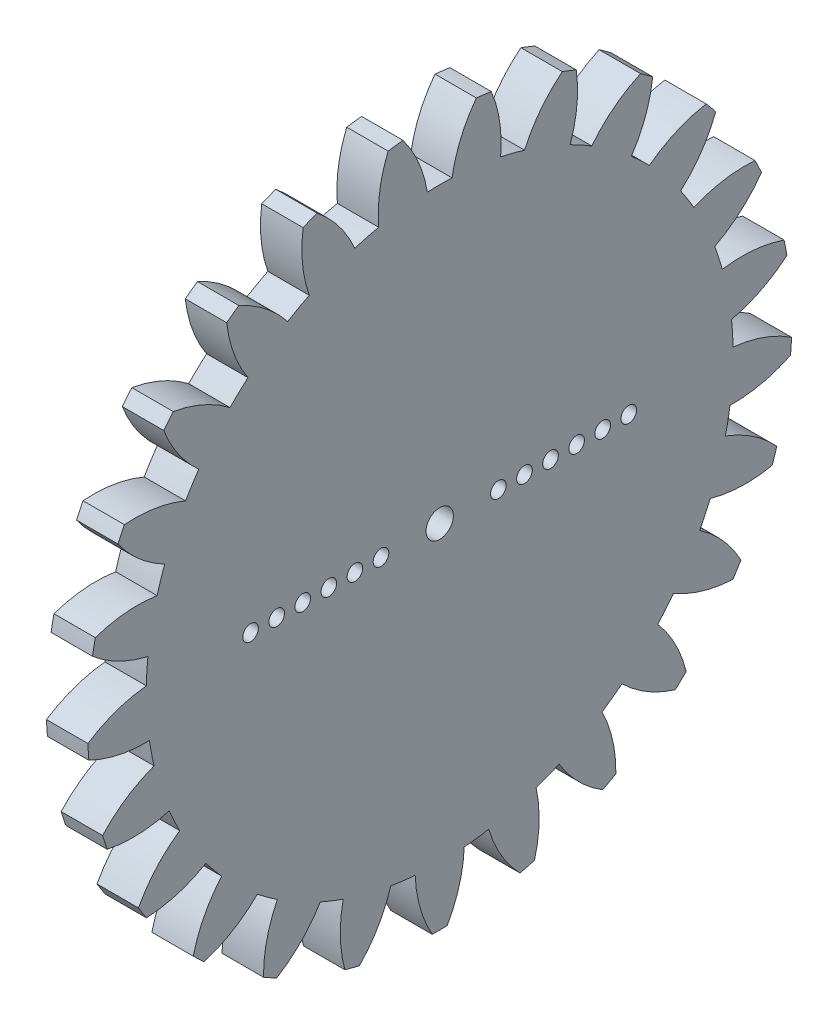
from build123d import *

# Parameters (mm, degrees)
BASPROSKE_W        = 10
BASPROSKE_H        = 27
TOOTHCUT_DEPTH     = 40.471508712
TEETHCUTS_COUNT    = 25
CUT_EXTRUDE1_DEPTH = 6.825
SKETCH2_R          = 1.05
SKETCH2_R_2        = 0.6
CUT_EXTRUDE2_DEPTH = 39.299167466


with BuildPart() as part:
    # BasProSke → Base-Revolve (revolve)
    with BuildSketch(Plane(origin=(0, 0, 0), x_dir=(1, 0, 0), z_dir=(0, 1, 0)), mode=Mode.PRIVATE) as base_revolve_sk:
        with Locations((5, 13.5)):
            Rectangle(BASPROSKE_W, BASPROSKE_H)
    revolve(base_revolve_sk.sketch.rotate(Axis((-10, 0, 0), (1, 0, 0)), 180), axis=Axis((-10, 0, 0), (1, 0, 0)))

    # TooCutSke → ToothCut (cut, through all)
    with BuildSketch(Plane(origin=(0, 0, 0), x_dir=(0, 0, -1), z_dir=(1, 0, 0))):
        with BuildLine():
            ThreePointArc((0.946154762, 22.479096783), (0, 22.499), (-0.946154762, 22.479096783))
            ThreePointArc((-0.946154762, 22.479096783), (-1.62094792, 24.792268013), (-2.829470045, 26.876873784))
            ThreePointArc((-2.829470045, 26.876873784), (0, 27.0254), (2.829470045, 26.876873784))
            ThreePointArc((2.829470045, 26.876873784), (1.62094792, 24.792268013), (0.946154762, 22.479096783))
        make_face()
    toothcut = extrude(amount=TOOTHCUT_DEPTH, mode=Mode.SUBTRACT)

    # TeethCuts: ToothCut ×25 about axis
    teethcuts_axis = Axis((0, 0, 0), (1, 0, 0))
    for i in range(1, TEETHCUTS_COUNT):
        add(toothcut.rotate(teethcuts_axis, i * 360 / TEETHCUTS_COUNT), mode=Mode.SUBTRACT)

    # Sketch1 → Cut-Extrude1 (cut)
    with BuildSketch(Plane(origin=(10, 0, 0), x_dir=(0, 0, -1), z_dir=(1, 0, 0))):
        with BuildLine():
            ThreePointArc((-26.623667603, 4.492251481), (-24.628342026, 3.167806143), (-22.375329871, 2.355761908))
            ThreePointArc((-22.375329871, 2.355761908), (-22.454603363, 1.412723899), (-22.494148969, 0.467186424))
            ThreePointArc((-22.494148969, 0.467186424), (-24.83117158, -0.056077302), (-26.976760436, -1.119998387))
            ThreePointArc((-26.976760436, -1.119998387), (-26.946721668, -1.695344027), (-26.904413642, -2.269917752))
            ThreePointArc((-26.904413642, -2.269917752), (-24.642398725, -3.056535912), (-22.258221901, -3.282766946))
            ThreePointArc((-22.258221901, -3.282766946), (-22.100480854, -4.215892197), (-21.903638454, -5.141558466))
            ThreePointArc((-21.903638454, -5.141558466), (-24.037108806, -6.229576789), (-25.850703628, -7.793659087))
            ThreePointArc((-25.850703628, -7.793659087), (-25.67852594, -8.343458848), (-25.494656424, -8.889459704))
            ThreePointArc((-25.494656424, -8.889459704), (-23.108082884, -9.088824574), (-20.742547988, -8.715027478))
            ThreePointArc((-20.742547988, -8.715027478), (-20.357703853, -9.579608281), (-19.93684178, -10.427240328))
            ThreePointArc((-19.93684178, -10.427240328), (-21.732706083, -12.011649055), (-23.100352038, -13.977615523))
            ThreePointArc((-23.100352038, -13.977615523), (-22.796853989, -14.467323464), (-22.48297618, -14.95044421))
            ThreePointArc((-22.48297618, -14.95044421), (-20.12180121, -14.550028962), (-17.9235435, -13.599690783))
            ThreePointArc((-17.9235435, -13.599690783), (-17.335777449, -14.341402345), (-16.717340013, -15.057740331))
            ThreePointArc((-16.717340013, -15.057740331), (-18.06275751, -17.038985236), (-18.898520373, -19.28330697))
            ThreePointArc((-18.898520373, -19.28330697), (-18.48277186, -19.68215294), (-18.058607856, -20.072037323))
            ThreePointArc((-18.058607856, -20.072037323), (-15.871192762, -19.097001519), (-13.978336856, -17.6298355))
            ThreePointArc((-13.978336856, -17.6298355), (-13.224580391, -18.202073356), (-12.447426292, -18.742107131))
            ThreePointArc((-12.447426292, -18.742107131), (-13.257859452, -20.995699309), (-13.509225169, -23.377357322))
            ThreePointArc((-13.509225169, -23.377357322), (-13.007349201, -23.660280361), (-12.499550786, -23.932430511))
            ThreePointArc((-12.499550786, -23.932430511), (-10.623338904, -22.444039237), (-9.154819898, -20.552232814))
            ThreePointArc((-9.154819898, -20.552232814), (-8.282434311, -20.919041156), (-7.395394998, -21.248838411))
            ThreePointArc((-7.395394998, -21.248838411), (-7.619921325, -23.633176378), (-7.271095664, -26.002522336))
            ThreePointArc((-7.271095664, -26.002522336), (-6.714626953, -26.15174535), (-6.15510097, -26.289061072))
            ThreePointArc((-6.15510097, -26.289061072), (-4.707981592, -24.380835426), (-3.756071937, -22.183257755))
            ThreePointArc((-3.756071937, -22.183257755), (-2.819872422, -22.321588665), (-1.878683838, -22.420427026))
            ThreePointArc((-1.878683838, -22.420427026), (-1.503195518, -24.785694058), (-0.576096477, -26.993853242))
            ThreePointArc((-0.576096477, -26.993853242), (0, -27), (0.576096477, -26.993853242))
            ThreePointArc((0.576096477, -26.993853242), (1.503195518, -24.785694058), (1.878683838, -22.420427026))
            ThreePointArc((1.878683838, -22.420427026), (2.819872422, -22.321588665), (3.756071937, -22.183257755))
            ThreePointArc((3.756071937, -22.183257755), (4.707981592, -24.380835426), (6.15510097, -26.289061072))
            ThreePointArc((6.15510097, -26.289061072), (6.714626953, -26.15174535), (7.271095664, -26.002522336))
            ThreePointArc((7.271095664, -26.002522336), (7.619921325, -23.633176378), (7.395394998, -21.248838411))
            ThreePointArc((7.395394998, -21.248838411), (8.282434311, -20.919041156), (9.154819898, -20.552232814))
            ThreePointArc((9.154819898, -20.552232814), (10.623338904, -22.444039237), (12.499550786, -23.932430511))
            ThreePointArc((12.499550786, -23.932430511), (13.007349201, -23.660280361), (13.509225169, -23.377357322))
            ThreePointArc((13.509225169, -23.377357322), (13.257859452, -20.995699309), (12.447426292, -18.742107131))
            ThreePointArc((12.447426292, -18.742107131), (13.224580391, -18.202073356), (13.978336856, -17.6298355))
            ThreePointArc((13.978336856, -17.6298355), (15.871192762, -19.097001519), (18.058607856, -20.072037323))
            ThreePointArc((18.058607856, -20.072037323), (18.48277186, -19.68215294), (18.898520373, -19.28330697))
            ThreePointArc((18.898520373, -19.28330697), (18.06275751, -17.038985236), (16.717340013, -15.057740331))
            ThreePointArc((16.717340013, -15.057740331), (17.335777449, -14.341402345), (17.9235435, -13.599690783))
            ThreePointArc((17.9235435, -13.599690783), (20.12180121, -14.550028962), (22.48297618, -14.95044421))
            ThreePointArc((22.48297618, -14.95044421), (22.796853989, -14.467323464), (23.100352038, -13.977615523))
            ThreePointArc((23.100352038, -13.977615523), (21.732706083, -12.011649055), (19.93684178, -10.427240328))
            ThreePointArc((19.93684178, -10.427240328), (20.357703853, -9.579608281), (20.742547988, -8.715027478))
            ThreePointArc((20.742547988, -8.715027478), (23.108082884, -9.088824574), (25.494656424, -8.889459704))
            ThreePointArc((25.494656424, -8.889459704), (25.67852594, -8.343458848), (25.850703628, -7.793659087))
            ThreePointArc((25.850703628, -7.793659087), (24.037108806, -6.229576789), (21.903638454, -5.141558466))
            ThreePointArc((21.903638454, -5.141558466), (22.100480854, -4.215892197), (22.258221901, -3.282766946))
            ThreePointArc((22.258221901, -3.282766946), (24.642398725, -3.056535912), (26.904413642, -2.269917752))
            ThreePointArc((26.904413642, -2.269917752), (26.946721668, -1.695344027), (26.976760436, -1.119998387))
            ThreePointArc((26.976760436, -1.119998387), (24.83117158, -0.056077302), (22.494148969, 0.467186424))
            ThreePointArc((22.494148969, 0.467186424), (22.454603363, 1.412723899), (22.375329871, 2.355761908))
            ThreePointArc((22.375329871, 2.355761908), (24.628342026, 3.167806143), (26.623667603, 4.492251481))
            ThreePointArc((26.623667603, 4.492251481), (26.52175577, 5.059295494), (26.407768172, 5.624035931))
            ThreePointArc((26.407768172, 5.624035931), (24.065000522, 6.120945728), (21.671269376, 6.046576272))
            ThreePointArc((21.671269376, 6.046576272), (21.39782056, 6.952573356), (21.086513575, 7.846269576))
            ThreePointArc((21.086513575, 7.846269576), (23.066796021, 9.193103287), (24.670058614, 10.972156033))
            ThreePointArc((24.670058614, 10.972156033), (24.430330417, 11.496040872), (24.179478714, 12.014691387))
            ThreePointArc((24.179478714, 12.014691387), (21.786736975, 11.913367227), (19.486704228, 11.246037495))
            ThreePointArc((19.486704228, 11.246037495), (18.996533996, 12.05556706), (18.47275408, 12.843767271))
            ThreePointArc((18.47275408, 12.843767271), (20.055878388, 14.640763942), (21.166339111, 16.762639667))
            ThreePointArc((21.166339111, 16.762639667), (20.803857555, 17.210447723), (20.431903681, 17.650419597))
            ThreePointArc((20.431903681, 17.650419597), (18.139532619, 16.957228049), (16.077717785, 15.738868823))
            ThreePointArc((16.077717785, 15.738868823), (15.401625336, 16.401065148), (14.698283508, 17.034243832))
            ThreePointArc((14.698283508, 17.034243832), (15.784776155, 19.168491554), (16.332660679, 21.499865003))
            ThreePointArc((16.332660679, 21.499865003), (15.870201812, 21.843458848), (15.400516998, 22.17710703))
            ThreePointArc((15.400516998, 22.17710703), (13.352554715, 20.935603868), (11.658509204, 19.242769139))
            ThreePointArc((11.658509204, 19.242769139), (10.838975914, 19.716023994), (10.000265727, 20.154396205))
            ThreePointArc((10.000265727, 20.154396205), (10.521858385, 22.491792344), (10.472741108, 24.88617475))
            ThreePointArc((10.472741108, 24.88617475), (9.939362922, 25.103965119), (9.401459192, 25.310325266))
            ThreePointArc((9.401459192, 25.310325266), (7.726586692, 23.5985187), (6.506753613, 21.5375755))
            ThreePointArc((6.506753613, 21.5375755), (5.595273771, 21.792152542), (4.673894472, 22.008173742))
            ThreePointArc((4.673894472, 22.008173742), (4.597813555, 24.401851103), (3.954780698, 26.708794612))
            ThreePointArc((3.954780698, 26.708794612), (3.383997306, 26.787096935), (2.811673129, 26.853202681))
            ThreePointArc((2.811673129, 26.853202681), (1.61512881, 24.778651813), (0.946154762, 22.479096783))
            ThreePointArc((0.946154762, 22.479096783), (0, 22.499), (-0.946154762, 22.479096783))
            ThreePointArc((-0.946154762, 22.479096783), (-1.61512881, 24.778651813), (-2.811673129, 26.853202681))
            ThreePointArc((-2.811673129, 26.853202681), (-3.383997306, 26.787096935), (-3.954780698, 26.708794612))
            ThreePointArc((-3.954780698, 26.708794612), (-4.597813555, 24.401851103), (-4.673894472, 22.008173742))
            ThreePointArc((-4.673894472, 22.008173742), (-5.595273771, 21.792152542), (-6.506753613, 21.5375755))
            ThreePointArc((-6.506753613, 21.5375755), (-7.726586692, 23.5985187), (-9.401459192, 25.310325266))
            ThreePointArc((-9.401459192, 25.310325266), (-9.939362922, 25.103965119), (-10.472741108, 24.88617475))
            ThreePointArc((-10.472741108, 24.88617475), (-10.521858385, 22.491792344), (-10.000265727, 20.154396205))
            ThreePointArc((-10.000265727, 20.154396205), (-10.838975914, 19.716023994), (-11.658509204, 19.242769139))
            ThreePointArc((-11.658509204, 19.242769139), (-13.352554715, 20.935603868), (-15.400516998, 22.17710703))
            ThreePointArc((-15.400516998, 22.17710703), (-15.870201812, 21.843458848), (-16.332660679, 21.499865003))
            ThreePointArc((-16.332660679, 21.499865003), (-15.784776155, 19.168491554), (-14.698283508, 17.034243832))
            ThreePointArc((-14.698283508, 17.034243832), (-15.401625336, 16.401065148), (-16.077717785, 15.738868823))
            ThreePointArc((-16.077717785, 15.738868823), (-18.139532619, 16.957228049), (-20.431903681, 17.650419597))
            ThreePointArc((-20.431903681, 17.650419597), (-20.803857555, 17.210447723), (-21.166339111, 16.762639667))
            ThreePointArc((-21.166339111, 16.762639667), (-20.055878388, 14.640763942), (-18.47275408, 12.843767271))
            ThreePointArc((-18.47275408, 12.843767271), (-18.996533996, 12.05556706), (-19.486704228, 11.246037495))
            ThreePointArc((-19.486704228, 11.246037495), (-21.786736975, 11.913367227), (-24.179478714, 12.014691387))
            ThreePointArc((-24.179478714, 12.014691387), (-24.430330417, 11.496040872), (-24.670058614, 10.972156033))
            ThreePointArc((-24.670058614, 10.972156033), (-23.066796021, 9.193103287), (-21.086513575, 7.846269576))
            ThreePointArc((-21.086513575, 7.846269576), (-21.39782056, 6.952573356), (-21.671269376, 6.046576272))
            ThreePointArc((-21.671269376, 6.046576272), (-24.065000522, 6.120945728), (-26.407768172, 5.624035931))
            ThreePointArc((-26.407768172, 5.624035931), (-26.52175577, 5.059295494), (-26.623667603, 4.492251481))
        make_face()
    extrude(amount=-CUT_EXTRUDE1_DEPTH, mode=Mode.SUBTRACT)

    # Sketch2 → Cut-Extrude2 (cut, through all)
    with BuildSketch(Plane.ZY):
        Circle(SKETCH2_R)
        with Locations((4.5, 0)):
            Circle(SKETCH2_R_2)
        with Locations((6.5, 0)):
            Circle(SKETCH2_R_2)
        with Locations((8.5, 0)):
            Circle(SKETCH2_R_2)
        with Locations((10.5, 0)):
            Circle(SKETCH2_R_2)
        with Locations((12.5, 0)):
            Circle(SKETCH2_R_2)
        with Locations((14.5, 0)):
            Circle(SKETCH2_R_2)
        with Locations(Location((-14.5, 0, 0), (0, 0, 180))):
            Circle(SKETCH2_R_2)
        with Locations(Location((-12.5, 0, 0), (0, 0, 180))):
            Circle(SKETCH2_R_2)
        with Locations(Location((-10.5, 0, 0), (0, 0, 180))):
            Circle(SKETCH2_R_2)
        with Locations(Location((-8.5, 0, 0), (0, 0, 180))):
            Circle(SKETCH2_R_2)
        with Locations(Location((-6.5, 0, 0), (0, 0, 180))):
            Circle(SKETCH2_R_2)
        with Locations(Location((-4.5, 0, 0), (0, 0, 180))):
            Circle(SKETCH2_R_2)
    extrude(amount=-CUT_EXTRUDE2_DEPTH, mode=Mode.SUBTRACT)


solid = part.part
